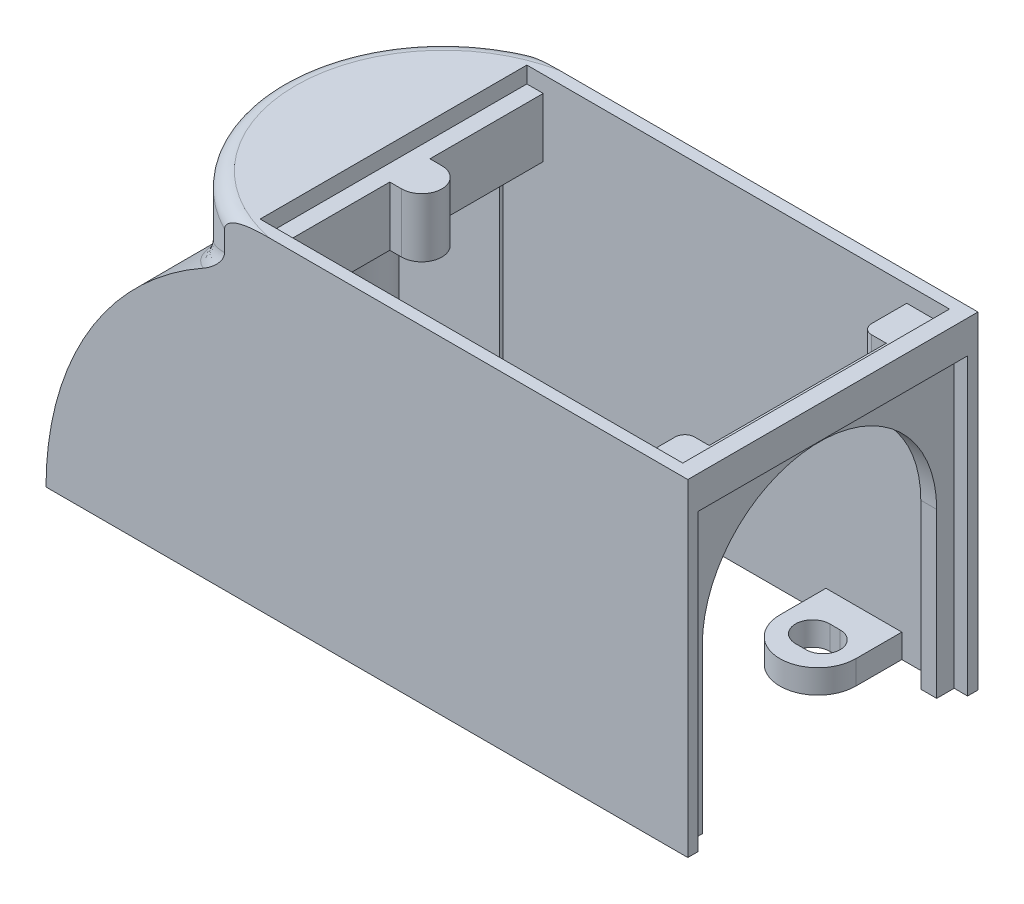
from build123d import *

# Parameters (mm, degrees)
SKETCH1_W                = 75
SKETCH1_H                = 49.53
BOSS_EXTRUDE1_DEPTH      = 55.88
CUT_EXTRUDE1_DEPTH       = 51.816
SKETCH3_W                = 8.546
SKETCH3_H                = 45.53
CUT_EXTRUDE2_DEPTH       = 43
SKETCH5_R                = 20.0025
CUT_EXTRUDE3_DEPTH       = 53.454
CUT_EXTRUDE4_DEPTH       = 2.794
CUT_EXTRUDE5_REACH       = 105.619
SKETCH9_W                = 5
SKETCH9_H                = 40.005
CUT_EXTRUDE6_DEPTH       = 2.286
CUT_EXTRUDE7_DEPTH       = 2.794
BOSS_EXTRUDE2_DEPTH      = 4.064
BOSS_EXTRUDE3_DEPTH      = 49.53
CUT_EXTRUDE8_DEPTH       = 49.53
BOSS_EXTRUDE4_DEPTH      = 2.6
BOSS_EXTRUDE5_DEPTH      = 2.6
BOSS_EXTRUDE6_REACH      = 107.834
BOSS_EXTRUDE6_END_RADIUS = 52.44703125
BOSS_EXTRUDE7_REACH      = 107.834
BOSS_EXTRUDE7_END_RADIUS = 50.44703125
SKETCH19_R               = 7.239
CUT_EXTRUDE9_START       = -4.318
SKETCH20_R               = 6.096
CUT_EXTRUDE9_DEPTH       = 102.515809915
FILLET1_R                = 2.54


with BuildPart() as part:
    # Sketch1 → Boss-Extrude1 (new body)
    with BuildSketch(Plane(origin=(0, 0, 0), x_dir=(1, 0, 0), z_dir=(0, 1, 0))):
        with Locations((37.5, 24.765)):
            Rectangle(SKETCH1_W, SKETCH1_H)
    extrude(amount=BOSS_EXTRUDE1_DEPTH)

    # Sketch2 → Cut-Extrude1 (cut)
    with BuildSketch(Plane(origin=(0, 55.88, 0), x_dir=(1, 0, 0), z_dir=(0, 1, 0))):
        with BuildLine():
            Line((64.84, 47.53), (2.794, 47.53))
            Line((2.794, 47.53), (2.794, 28.194))
            Line((2.794, 28.194), (4.826, 28.194))
            ThreePointArc((4.826, 28.194), (7.250669153, 27.189669153), (8.255, 24.765))
            ThreePointArc((8.255, 24.765), (7.250669153, 22.340330847), (4.826, 21.336))
            Line((4.826, 21.336), (2.794, 21.336))
            Line((2.794, 21.336), (2.794, 2))
            Line((2.794, 2), (64.84, 2))
            Line((64.84, 2), (64.84, 8.001))
            ThreePointArc((64.84, 8.001), (65.323566704, 9.168433296), (66.491, 9.652))
            Line((66.491, 9.652), (69, 9.652))
            Line((69, 9.652), (69, 24.765))
            Line((69, 24.765), (69, 39.878))
            Line((69, 39.878), (66.491, 39.878))
            ThreePointArc((66.491, 39.878), (65.323566704, 40.361566704), (64.84, 41.529))
            Line((64.84, 41.529), (64.84, 47.53))
        make_face()
    extrude(amount=-CUT_EXTRUDE1_DEPTH, mode=Mode.SUBTRACT)

    # Sketch3 → Cut-Extrude2 (cut)
    with BuildSketch(Plane.XZ):
        with BuildLine():
            Line((51.046, -47.53), (51.046, -39.673))
            ThreePointArc((51.046, -39.673), (57.523, -33.196), (64, -39.673))
            Line((64, -39.673), (64, -47.53))
            Line((64, -47.53), (70, -47.53))
            Line((70, -47.53), (70, -2.54))
            Line((70, -2.54), (70, -2))
            Line((70, -2), (64, -2))
            Line((64, -2), (64, -10.173))
            ThreePointArc((64, -10.173), (57.523, -16.65), (51.046, -10.173))
            Line((51.046, -10.173), (51.046, -2))
            Line((51.046, -2), (21.546, -2))
            Line((21.546, -2), (21.546, -47.53))
            Line((21.546, -47.53), (51.046, -47.53))
        make_face()
        with Locations((4.273, -24.765)):
            Rectangle(SKETCH3_W, SKETCH3_H)
        with BuildLine():
            Line((56.634, -42.594), (58.412, -42.594))
            ThreePointArc((58.412, -42.594), (61.333, -39.673), (58.412, -36.752))
            Line((58.412, -36.752), (56.634, -36.752))
            ThreePointArc((56.634, -36.752), (53.713, -39.673), (56.634, -42.594))
        make_face()
        with BuildLine():
            Line((56.634, -13.094), (58.412, -13.094))
            ThreePointArc((58.412, -13.094), (61.333, -10.173), (58.412, -7.252))
            Line((58.412, -7.252), (56.634, -7.252))
            ThreePointArc((56.634, -7.252), (53.713, -10.173), (56.634, -13.094))
        make_face()
    extrude(amount=-CUT_EXTRUDE2_DEPTH, mode=Mode.SUBTRACT)

    # Sketch5 → Cut-Extrude3 (cut)
    with BuildSketch(Plane(origin=(75, 0, 0), x_dir=(0, 0, -1), z_dir=(1, 0, 0))):
        with BuildLine():
            Line((4.7625, 27.94), (4.7625, 4.318))
            Line((4.7625, 4.318), (44.7675, 4.318))
            Line((44.7675, 4.318), (44.7675, 27.94))
            ThreePointArc((44.7675, 27.94), (24.765, 7.9375), (4.7625, 27.94))
        make_face()
        with Locations((24.765, 27.94)):
            Circle(SKETCH5_R)
    extrude(amount=-CUT_EXTRUDE3_DEPTH, mode=Mode.SUBTRACT)

    # Sketch8 → Cut-Extrude4 (cut)
    with BuildSketch(Plane(origin=(0, 55.88, 0), x_dir=(1, 0, 0), z_dir=(0, 1, 0))):
        with BuildLine():
            Line((72.136, 2), (72.136, 47.53))
            Line((72.136, 47.53), (64.84, 47.53))
            Line((64.84, 47.53), (64.84, 41.529))
            ThreePointArc((64.84, 41.529), (65.323566704, 40.361566704), (66.491, 39.878))
            Line((66.491, 39.878), (69, 39.878))
            Line((69, 39.878), (69, 9.652))
            Line((69, 9.652), (66.491, 9.652))
            ThreePointArc((66.491, 9.652), (65.323566704, 9.168433296), (64.84, 8.001))
            Line((64.84, 8.001), (64.84, 2))
            Line((64.84, 2), (72.136, 2))
        make_face()
    extrude(amount=-CUT_EXTRUDE4_DEPTH, mode=Mode.SUBTRACT)

    # Sketch9 → Cut-Extrude5 (cut, up to next)
    with BuildSketch(Plane(origin=(0, 4.318, 0), x_dir=(1, 0, 0), z_dir=(0, 1, 0)), mode=Mode.PRIVATE) as cut_extrude5_sk1:
        with Locations((72.5, 24.765)):
            Rectangle(SKETCH9_W, SKETCH9_H)
    cut_extrude5_tool1 = extrude(cut_extrude5_sk1.sketch, amount=-CUT_EXTRUDE5_REACH, mode=Mode.PRIVATE) & part.part
    add(cut_extrude5_tool1.solids().sort_by_distance((72.5, 4.318, -24.765))[0], mode=Mode.SUBTRACT)

    # Sketch10 → Cut-Extrude6 (cut)
    with BuildSketch(Plane(origin=(75, 0, 0), x_dir=(0, 0, -1), z_dir=(1, 0, 0))):
        with BuildLine():
            Line((1.778, 50.292), (1.778, 0))
            Line((1.778, 0), (4.7625, 0))
            Line((4.7625, 0), (4.7625, 27.94))
            ThreePointArc((4.7625, 27.94), (24.765, 47.9425), (44.7675, 27.94))
            Line((44.7675, 27.94), (44.7675, 0))
            Line((44.7675, 0), (47.752, 0))
            Line((47.752, 0), (47.752, 50.292))
            Line((47.752, 50.292), (1.778, 50.292))
        make_face()
    extrude(amount=-CUT_EXTRUDE6_DEPTH, mode=Mode.SUBTRACT)

    # Sketch11 → Cut-Extrude7 (cut)
    with BuildSketch(Plane(origin=(0, 55.88, 0), x_dir=(1, 0, 0), z_dir=(0, 1, 0))):
        with BuildLine():
            Line((2.794, 28.194), (2.794, 47.53))
            Line((2.794, 47.53), (0, 47.53))
            Line((0, 47.53), (0, 2))
            Line((0, 2), (2.794, 2))
            Line((2.794, 2), (2.794, 21.336))
            Line((2.794, 21.336), (4.12460211, 21.336))
            ThreePointArc((4.12460211, 21.336), (8.326, 24.765), (4.12460211, 28.194))
            Line((4.12460211, 28.194), (2.794, 28.194))
        make_face()
    extrude(amount=-CUT_EXTRUDE7_DEPTH, mode=Mode.SUBTRACT)

    # Sketch12 → Boss-Extrude2 (add)
    with BuildSketch(Plane.ZY):
        Polygon((-49.53, 55.88), (-49.53, 0), (-47.53, 0), (-47.53, 43), (-2, 43), (-2, 0), (0, 0), (0, 55.88), align=None)
    extrude(amount=BOSS_EXTRUDE2_DEPTH)

    # Sketch13 → Boss-Extrude3 (add)
    with BuildSketch(Plane.XY):
        with BuildLine():
            Line((-4.064, 0), (-4.064, 47.625))
            ThreePointArc((-4.064, 47.625), (-26.271603221, 28.271766062), (-34.544, 0))
            Line((-34.544, 0), (-4.064, 0))
        make_face()
    extrude(amount=-BOSS_EXTRUDE3_DEPTH)

    # Sketch14 → Cut-Extrude8 (cut)
    with BuildSketch(Plane.XY):
        with BuildLine():
            Line((-32.544, 0), (-4.064, 0))
            Line((-4.064, 0), (-4.064, 45.413131361))
            ThreePointArc((-4.064, 45.413131361), (-24.834975687, 26.802345513), (-32.544, 0))
        make_face()
    extrude(amount=-CUT_EXTRUDE8_DEPTH, mode=Mode.SUBTRACT)

    # Sketch15 → Boss-Extrude4 (add)
    with BuildSketch(Plane.XY):
        with BuildLine():
            ThreePointArc((-4.064, 45.413131361), (-24.834975687, 26.802345513), (-32.544, 0))
            Line((-32.544, 0), (-4.064, 0))
            Line((-4.064, 0), (-4.064, 45.413131361))
        make_face()
    extrude(amount=-BOSS_EXTRUDE4_DEPTH)

    # Sketch16 → Boss-Extrude5 (add)
    with BuildSketch(Plane(origin=(0, 0, -49.53), x_dir=(-1, 0, 0), z_dir=(0, 0, -1))):
        with BuildLine():
            ThreePointArc((32.544, 0), (24.834975687, 26.802345513), (4.064, 45.413131361))
            Line((4.064, 45.413131361), (4.064, 0))
            Line((4.064, 0), (32.544, 0))
        make_face()
    extrude(amount=-BOSS_EXTRUDE5_DEPTH)

    # Boss-Extrude6: up to this cylinder (the profile starts outside it)
    boss_extrude6_end = Plane(origin=(17.90303125, 0, -24.765), z_dir=(0, 0, 1)) * Cylinder(BOSS_EXTRUDE6_END_RADIUS, 321.5620625, mode=Mode.PRIVATE)
    # Sketch18 → Boss-Extrude6 (add, up to the surface)
    with BuildSketch(Plane(origin=(0, 55.88, 0), x_dir=(1, 0, 0), z_dir=(0, 1, 0)), mode=Mode.PRIVATE) as boss_extrude6_sk1:
        with BuildLine():
            Line((-4.064, 0), (-4.064, 49.53))
            ThreePointArc((-4.064, 49.53), (-19.244597781, 24.765), (-4.064, 0))
        make_face()
    boss_extrude6_tool1 = extrude(boss_extrude6_sk1.sketch, amount=-BOSS_EXTRUDE6_REACH, mode=Mode.PRIVATE) - boss_extrude6_end
    add(boss_extrude6_tool1.solids().sort_by_distance((-10.305482, 55.88, -24.765))[0])

    # Boss-Extrude7: up to this cylinder (the profile starts inside it)
    boss_extrude7_end = Plane(origin=(17.90303125, 0, -24.765), z_dir=(0, 0, 1)) * Cylinder(BOSS_EXTRUDE7_END_RADIUS, 349.5700625, mode=Mode.PRIVATE)
    # Sketch19 → Boss-Extrude7 (add, up to the surface)
    with BuildSketch(Plane.XZ, mode=Mode.PRIVATE) as boss_extrude7_sk1:
        with Locations((-25.283, -8.761)):
            Circle(SKETCH19_R)
        with BuildLine():
            Line((-26.172, -5.84), (-24.394, -5.84))
            ThreePointArc((-24.394, -5.84), (-21.473, -8.761), (-24.394, -11.682))
            Line((-24.394, -11.682), (-26.172, -11.682))
            ThreePointArc((-26.172, -11.682), (-29.093, -8.761), (-26.172, -5.84))
        make_face(mode=Mode.SUBTRACT)
    boss_extrude7_tool1 = extrude(boss_extrude7_sk1.sketch, amount=-BOSS_EXTRUDE7_REACH, mode=Mode.PRIVATE) & boss_extrude7_end
    add(boss_extrude7_tool1.solids().sort_by_distance((-32.31725, 0, -8.761))[0])
    # Sketch19 → Boss-Extrude7 (add, up to the surface)
    with BuildSketch(Plane.XZ, mode=Mode.PRIVATE) as boss_extrude7_sk2:
        with Locations((-25.283, -40.769)):
            Circle(SKETCH19_R)
        with BuildLine():
            Line((-26.172, -37.848), (-24.394, -37.848))
            ThreePointArc((-24.394, -37.848), (-21.473, -40.769), (-24.394, -43.69))
            Line((-24.394, -43.69), (-26.172, -43.69))
            ThreePointArc((-26.172, -43.69), (-29.093, -40.769), (-26.172, -37.848))
        make_face(mode=Mode.SUBTRACT)
    boss_extrude7_tool2 = extrude(boss_extrude7_sk2.sketch, amount=-BOSS_EXTRUDE7_REACH, mode=Mode.PRIVATE) & boss_extrude7_end
    add(boss_extrude7_tool2.solids().sort_by_distance((-32.31725, 0, -40.769))[0])

    # Sketch20 → Cut-Extrude9 (cut, through all)
    with BuildSketch(Plane.XZ.offset(CUT_EXTRUDE9_START)):
        with Locations(Location((-25.283, -8.761, 0), (0, 0, 270))):
            Circle(SKETCH20_R)
        with BuildLine():
            ThreePointArc((-24.394, -11.682), (-21.473, -8.761), (-24.394, -5.84))
            Line((-24.394, -5.84), (-26.172, -5.84))
            ThreePointArc((-26.172, -5.84), (-29.093, -8.761), (-26.172, -11.682))
            Line((-26.172, -11.682), (-24.394, -11.682))
        make_face(mode=Mode.SUBTRACT)
        with BuildLine():
            Line((-26.172, -11.682), (-24.394, -11.682))
            ThreePointArc((-24.394, -11.682), (-21.473, -8.761), (-24.394, -5.84))
            Line((-24.394, -5.84), (-26.172, -5.84))
            ThreePointArc((-26.172, -5.84), (-29.093, -8.761), (-26.172, -11.682))
        make_face()
        with Locations(Location((-25.283, -40.769, 0), (0, 0, 270))):
            Circle(SKETCH20_R)
        with BuildLine():
            ThreePointArc((-24.394, -43.69), (-21.473, -40.769), (-24.394, -37.848))
            Line((-24.394, -37.848), (-26.172, -37.848))
            ThreePointArc((-26.172, -37.848), (-29.093, -40.769), (-26.172, -43.69))
            Line((-26.172, -43.69), (-24.394, -43.69))
        make_face(mode=Mode.SUBTRACT)
        with BuildLine():
            Line((-26.172, -43.69), (-24.394, -43.69))
            ThreePointArc((-24.394, -43.69), (-21.473, -40.769), (-24.394, -37.848))
            Line((-24.394, -37.848), (-26.172, -37.848))
            ThreePointArc((-26.172, -37.848), (-29.093, -40.769), (-26.172, -43.69))
        make_face()
    extrude(amount=-CUT_EXTRUDE9_DEPTH, mode=Mode.SUBTRACT)

    # Fillet1
    fillet1_edges = [part.edges().sort_by_distance(p)[0] for p in [
        (-19.244597781, 55.88, -24.765),
        (-19.244597781, 37.023570119, -24.765),
    ]]
    fillet(fillet1_edges, radius=FILLET1_R)


solid = part.part
